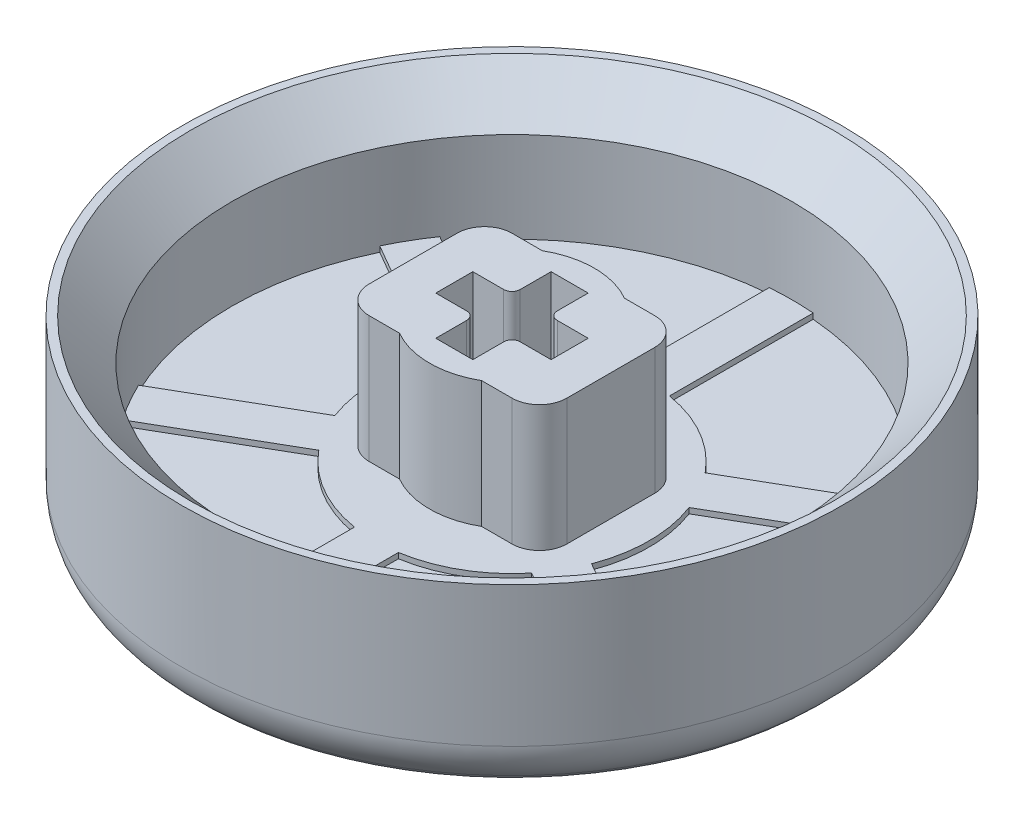
from build123d import *

# Parameters (mm, degrees)
SKETCH1_R          = 12
BUTTON_TOP_DEPTH   = 1.8
SKETCH2_R          = 12
SKETCH2_R_2        = 10.2
BUTTON_WALLS_DEPTH = 4.8
SKETCH5_R          = 5
OFFSET_2_DEPTH     = 0.2
STEM_START         = 0.2
STEM_HOUSING_DEPTH = 4.6
SPOKES_DEPTH       = 0.2
CHAMFER1_SIZE      = 1.5
FILLET2_R          = 1


with BuildPart() as part:
    # Sketch1 → button top (new body)
    with BuildSketch(Plane(origin=(0, 0, 0), x_dir=(1, 0, 0), z_dir=(0, 1, 0))):
        Circle(SKETCH1_R)
    extrude(amount=BUTTON_TOP_DEPTH)

    # Sketch2 → button walls (add)
    with BuildSketch(Plane(origin=(0, 1.8, 0), x_dir=(1, 0, 0), z_dir=(0, 1, 0))):
        Circle(SKETCH2_R)
        Circle(SKETCH2_R_2, mode=Mode.SUBTRACT)
    extrude(amount=BUTTON_WALLS_DEPTH)

    # Sketch5 → offset 2 (add)
    with BuildSketch(Plane(origin=(0, 1.8, 0), x_dir=(1, 0, 0), z_dir=(0, 1, 0))):
        Circle(SKETCH5_R)
    extrude(amount=OFFSET_2_DEPTH)

    # Sketch3 → stem housing (add)
    with BuildSketch(Plane(origin=(0, 1.8, 0), x_dir=(1, 0, 0), z_dir=(0, 1, 0)).offset(STEM_START)):
        with BuildLine():
            ThreePointArc((3, 0), (2.597112711, -1.501667596), (1.496662955, -2.6))
            Line((1.496662955, -2.6), (3.6, -2.6))
            Line((3.6, -2.6), (3.6, 2.6))
            Line((3.6, 2.6), (1.496662955, 2.6))
            ThreePointArc((1.496662955, 2.6), (2.597112711, 1.501667596), (3, 0))
        make_face()
        with BuildLine():
            ThreePointArc((-1.496662955, 2.6), (-3, 0), (-1.496662955, -2.6))
            Line((-1.496662955, -2.6), (1.496662955, -2.6))
            ThreePointArc((1.496662955, -2.6), (2.597112711, -1.501667596), (3, 0))
            ThreePointArc((3, 0), (2.597112711, 1.501667596), (1.496662955, 2.6))
            Line((1.496662955, 2.6), (-1.496662955, 2.6))
        make_face()
        with BuildLine():
            ThreePointArc((-0.975, 0.675), (-0.762867966, 0.762867966), (-0.675, 0.975))
            Line((-0.675, 0.975), (-0.675, 2.1))
            Line((-0.675, 2.1), (0.675, 2.1))
            Line((0.675, 2.1), (0.675, 0.975))
            ThreePointArc((0.675, 0.975), (0.762867966, 0.762867966), (0.975, 0.675))
            Line((0.975, 0.675), (2.1, 0.675))
            Line((2.1, 0.675), (2.1, -0.675))
            Line((2.1, -0.675), (0.975, -0.675))
            ThreePointArc((0.975, -0.675), (0.762867966, -0.762867966), (0.675, -0.975))
            Line((0.675, -0.975), (0.675, -2.1))
            Line((0.675, -2.1), (-0.675, -2.1))
            Line((-0.675, -2.1), (-0.675, -0.975))
            ThreePointArc((-0.675, -0.975), (-0.762867966, -0.762867966), (-0.975, -0.675))
            Line((-0.975, -0.675), (-2.1, -0.675))
            Line((-2.1, -0.675), (-2.1, 0.675))
            Line((-2.1, 0.675), (-0.975, 0.675))
        make_face(mode=Mode.SUBTRACT)
        with BuildLine():
            Line((1.496662955, -2.6), (-1.496662955, -2.6))
            ThreePointArc((-1.496662955, -2.6), (0, -3), (1.496662955, -2.6))
        make_face()
        with BuildLine():
            Line((-3.6, 2.6), (-3.6, -2.6))
            Line((-3.6, -2.6), (-1.496662955, -2.6))
            ThreePointArc((-1.496662955, -2.6), (-3, 0), (-1.496662955, 2.6))
            Line((-1.496662955, 2.6), (-3.6, 2.6))
        make_face()
        with BuildLine():
            ThreePointArc((1.496662955, 2.6), (0, 3), (-1.496662955, 2.6))
            Line((-1.496662955, 2.6), (1.496662955, 2.6))
        make_face()
    extrude(amount=STEM_HOUSING_DEPTH)

    # Sketch4 → spokes (add)
    with BuildSketch(Plane(origin=(0, 1.8, 0), x_dir=(1, 0, 0), z_dir=(0, 1, 0))):
        with BuildLine():
            Line((-0.8, 3.918501906), (-0.8, 10.2))
            ThreePointArc((-0.8, 10.2), (0, 11), (0.8, 10.2))
            Line((0.8, 10.2), (0.8, 3.918501906))
            ThreePointArc((0.8, 3.918501906), (0, 3.118501906), (-0.8, 3.918501906))
        make_face()
        with BuildLine():
            Line((-3.793522196, 1.26643063), (-9.233459119, 4.407179677))
            ThreePointArc((-9.233459119, 4.407179677), (-9.526279442, 5.5), (-8.433459119, 5.792820323))
            Line((-8.433459119, 5.792820323), (-2.993522196, 2.652071276))
            ThreePointArc((-2.993522196, 2.652071276), (-2.700701873, 1.559250953), (-3.793522196, 1.26643063))
        make_face()
        with BuildLine():
            Line((-2.993522196, -2.652071276), (-8.433459119, -5.792820323))
            ThreePointArc((-8.433459119, -5.792820323), (-9.526279442, -5.5), (-9.233459119, -4.407179677))
            Line((-9.233459119, -4.407179677), (-3.793522196, -1.26643063))
            ThreePointArc((-3.793522196, -1.26643063), (-2.700701873, -1.559250953), (-2.993522196, -2.652071276))
        make_face()
        with BuildLine():
            Line((0.8, -3.918501906), (0.8, -10.2))
            ThreePointArc((0.8, -10.2), (0, -11), (-0.8, -10.2))
            Line((-0.8, -10.2), (-0.8, -3.918501906))
            ThreePointArc((-0.8, -3.918501906), (0, -3.118501906), (0.8, -3.918501906))
        make_face()
        with BuildLine():
            Line((3.793522196, -1.26643063), (9.233459119, -4.407179677))
            ThreePointArc((9.233459119, -4.407179677), (9.526279442, -5.5), (8.433459119, -5.792820323))
            Line((8.433459119, -5.792820323), (2.993522196, -2.652071276))
            ThreePointArc((2.993522196, -2.652071276), (2.700701873, -1.559250953), (3.793522196, -1.26643063))
        make_face()
        with BuildLine():
            Line((2.993522196, 2.652071276), (8.433459119, 5.792820323))
            ThreePointArc((8.433459119, 5.792820323), (9.526279442, 5.5), (9.233459119, 4.407179677))
            Line((9.233459119, 4.407179677), (3.793522196, 1.26643063))
            ThreePointArc((3.793522196, 1.26643063), (2.700701873, 1.559250953), (2.993522196, 2.652071276))
        make_face()
    extrude(amount=SPOKES_DEPTH)

    # Chamfer1
    chamfer1_edges = [part.edges().sort_by_distance(p)[0] for p in [
        (-10.2, 6.6, 0),
    ]]
    chamfer(chamfer1_edges, length=CHAMFER1_SIZE)

    # Fillet2
    fillet2_edges = [part.edges().sort_by_distance(p)[0] for p in [
        (3.6, 4.3, 2.6),
        (3.6, 4.3, -2.6),
        (-3.6, 4.3, -2.6),
        (-3.6, 4.3, 2.6),
    ]]
    fillet(fillet2_edges, radius=FILLET2_R)

    # Sketch6 → Cut-Revolve1 (revolve, cut)
    with BuildSketch(Plane.XY):
        with BuildLine():
            Line((-11.261522369, 0), (-11.461522369, 0.2))
            ThreePointArc((-11.461522369, 0.2), (-11.860054223, 0.79644507), (-12, 1.5))
            Line((-12, 1.5), (-12, 0))
            Line((-12, 0), (-11.261522369, 0))
        make_face()
    revolve(axis=Axis((0, 0, 0), (0, 1, 0)), mode=Mode.SUBTRACT)


solid = part.part
